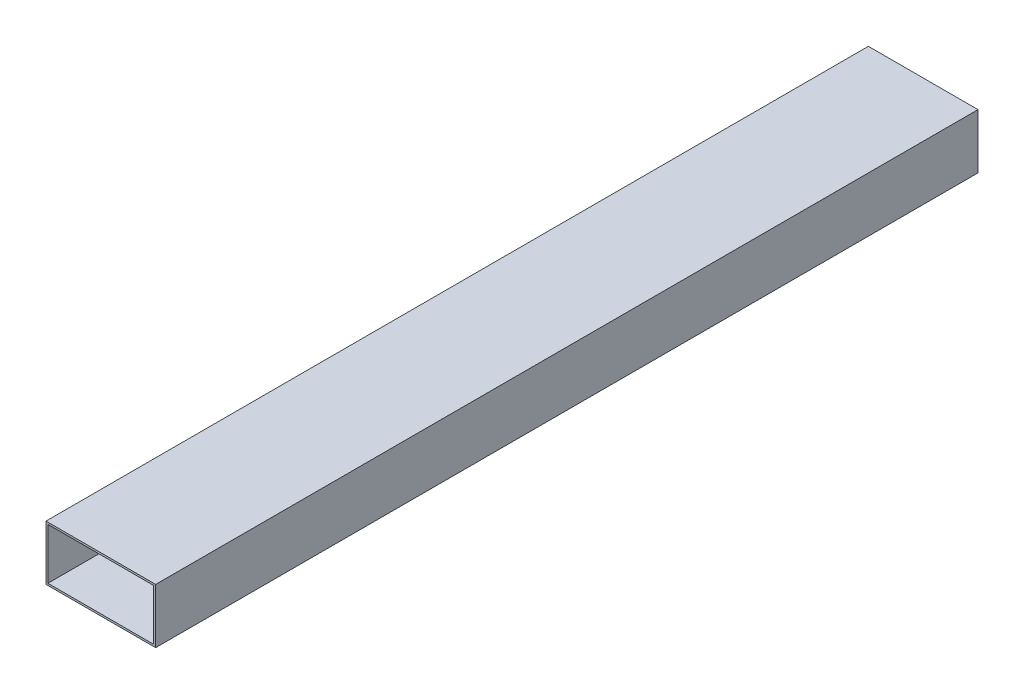
from build123d import *

# Parameters (mm, degrees)
SKETCH1_W           = 50.8
SKETCH1_H           = 25.4
SKETCH1_W_2         = 49.022
SKETCH1_H_2         = 23.622
BOSS_EXTRUDE1_DEPTH = 190.5


with BuildPart() as part:
    # Sketch1 → Boss-Extrude1 (new, symmetric)
    with BuildSketch(Plane.XY):
        Rectangle(SKETCH1_W, SKETCH1_H)
        Rectangle(SKETCH1_W_2, SKETCH1_H_2, mode=Mode.SUBTRACT)
    extrude(amount=BOSS_EXTRUDE1_DEPTH, both=True)


solid = part.part
